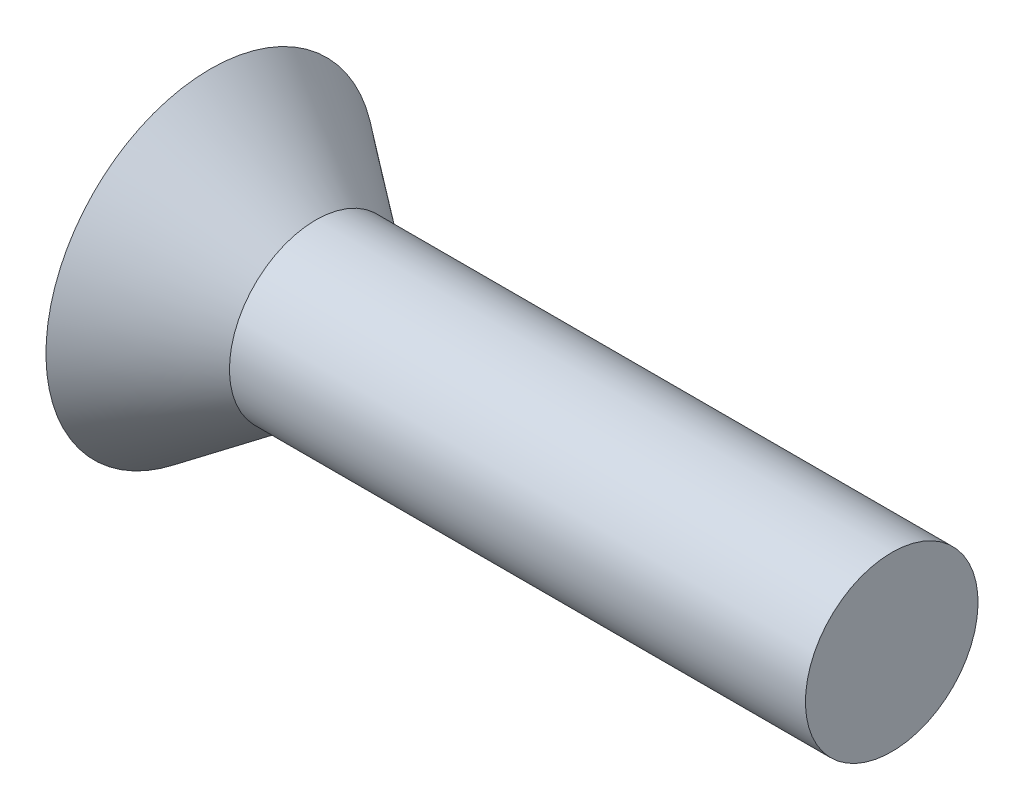
from build123d import *


with BuildPart() as part:
    # Sketch1 → Revolve1 (revolve)
    with BuildSketch(Plane.XY):
        Polygon((0, 0), (16.1036, 0), (16.1036, 2.413), (-2.9464, 2.413), (-2.9464, -2.1844), align=None)
    revolve(axis=Axis((22.164862166, 2.413, 0), (-1, 0, 0)))


solid = part.part
